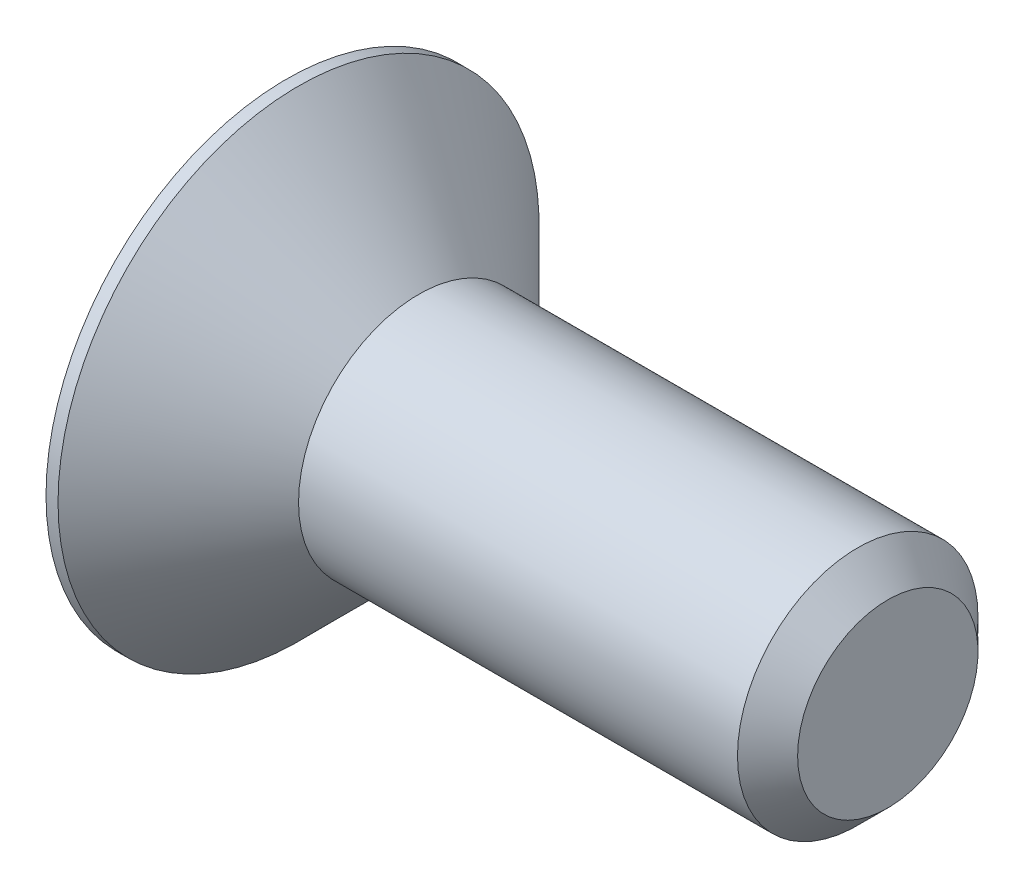
from build123d import *

# Parameters (mm, degrees)
CUT_EXTRUDE1_DEPTH = 0.8


with BuildPart() as part:
    # Sketch2 → Revolve1 (revolve)
    with BuildSketch(Plane.XY):
        Polygon((0, 0), (0, 2), (0.1, 2), (1.1, 1), (4.75, 1), (5, 0.75), (5, 0), align=None)
    revolve(axis=Axis((-2.281841559, 0, 0), (1, 0, 0)))

    # Sketch3 → Cut-Extrude1 (cut)
    with BuildSketch(Plane.ZY):
        Polygon((0.433012702, -0.75), (0.866025404, 0), (0.433012702, 0.75), (-0.433012702, 0.75), (-0.866025404, 0), (-0.433012702, -0.75), align=None)
    extrude(amount=-CUT_EXTRUDE1_DEPTH, mode=Mode.SUBTRACT)


solid = part.part
